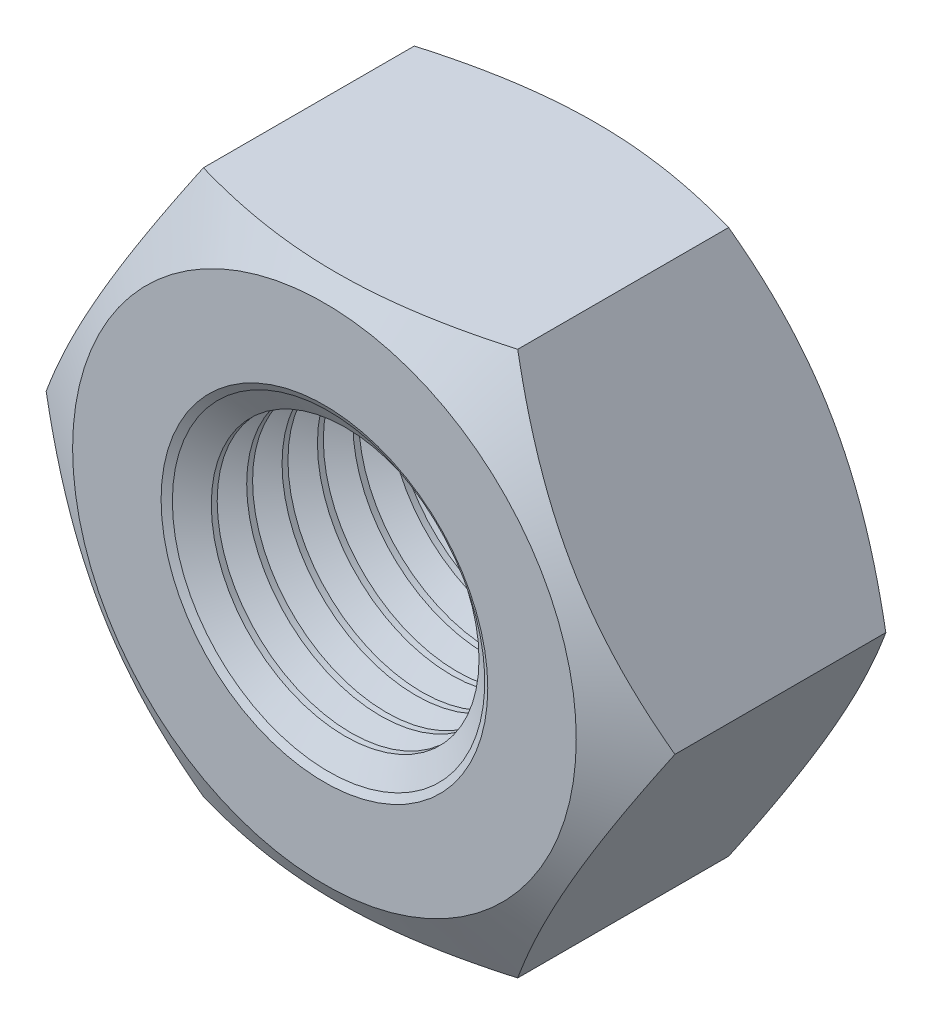
from build123d import *

# Parameters (mm, degrees)
SKETCH1_R               = 2.4585
BASENUT_DEPTH           = 5.2
ENDCHAMFER_SIZE         = 0.5415
ENDCHAMFER_SIZE2        = 0.312635171
ENDCHAMFER_PART_2_SIZE  = 0.5415
ENDCHAMFER_PART_2_SIZE2 = 0.312635171
LPATTERN10_COUNT        = 8
LPATTERN10_PITCH        = 0.6498


with BuildPart() as part:
    # Sketch1 → BaseNut (new body)
    with BuildSketch(Plane.XY):
        Polygon((5.773502692, 0), (2.886751346, 5), (-2.886751346, 5), (-5.773502692, 0), (-2.886751346, -5), (2.886751346, -5), align=None)
        Circle(SKETCH1_R, mode=Mode.SUBTRACT)
    extrude(amount=-BASENUT_DEPTH)

    # Sketch2 → Double-Chamfer (revolve, cut)
    with BuildSketch(Plane(origin=(0, 0, 0), x_dir=(1, 0, 0), z_dir=(0, 1, 0))):
        Polygon((-5.773502692, 5.2), (-4.625, 5.2), (-5.773502692, 4.536911662), align=None)
        Polygon((-5.773502692, 0.663088338), (-5.773502692, 0), (-4.625, 0), align=None)
    revolve(axis=Axis((0, 0, -3.375940562), (0, 0, 1)), mode=Mode.SUBTRACT)

    # EndChamfer
    endchamfer_edges = [part.edges().sort_by_distance(p)[0] for p in [
        (-2.4585, 0, -5.2),
    ]]
    endchamfer_side = [part.faces().sort_by_distance(p)[0] for p in [
        (-2.4585, 0, -2.6),
    ]]
    chamfer(endchamfer_edges, length=ENDCHAMFER_SIZE, length2=ENDCHAMFER_SIZE2, reference=endchamfer_side[0])

    # EndChamfer part 2
    endchamfer_part_2_edges = [part.edges().sort_by_distance(p)[0] for p in [
        (-2.4585, 0, 0),
    ]]
    endchamfer_part_2_side = [part.faces().sort_by_distance(p)[0] for p in [
        (4.494185245, 0, 0),
    ]]
    chamfer(endchamfer_part_2_edges, length=ENDCHAMFER_PART_2_SIZE, length2=ENDCHAMFER_PART_2_SIZE2, reference=endchamfer_part_2_side[0])

    # Sketch3 → Cut-Revolve10 (revolve, cut)
    with BuildSketch(Plane(origin=(0, 0, 0), x_dir=(1, 0, 0), z_dir=(0, 1, 0))):
        Polygon((-2.927452756, 4.6585), (-2.4585, 4.38775), (-1.917, 4.38775), (-1.917, 4.92925), (-2.4585, 4.92925), align=None)
    cut_revolve10 = revolve(axis=Axis((0, 0, -7.438254559), (0, 0, -1)), mode=Mode.SUBTRACT)

    # LPattern10: Cut-Revolve10 ×8
    with Locations(*[(0, 0, i * LPATTERN10_PITCH) for i in range(1, LPATTERN10_COUNT)]):
        add(cut_revolve10, mode=Mode.SUBTRACT)


solid = part.part
